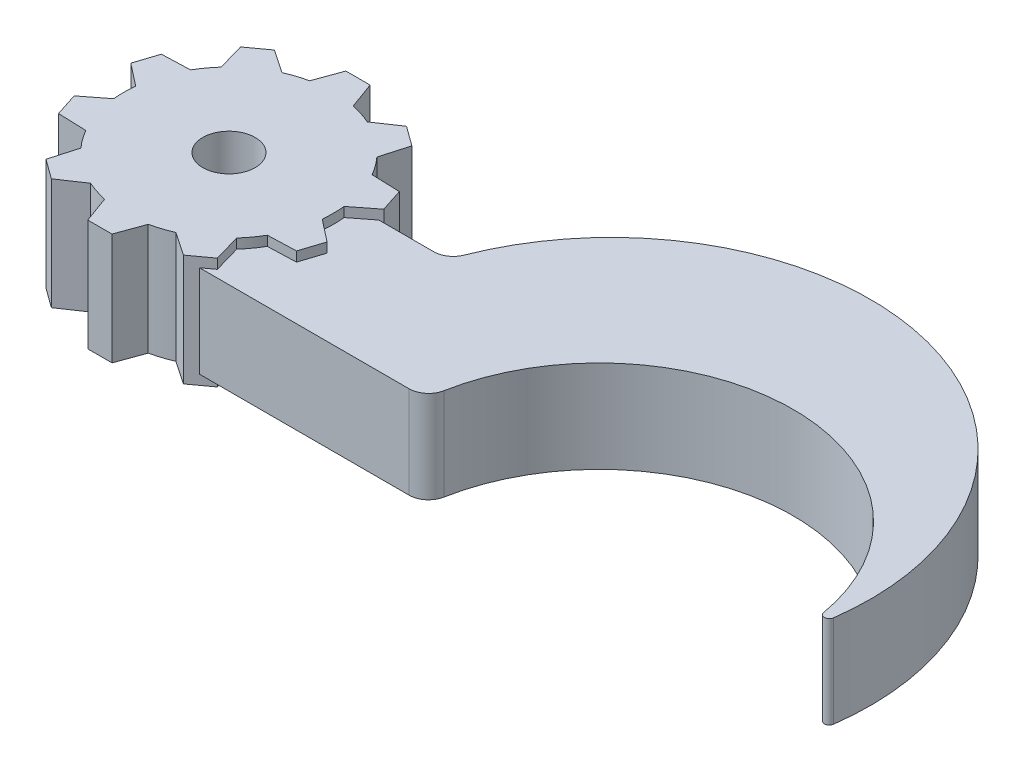
from build123d import *

# Parameters (mm, degrees)
SKETCH1_R           = 2.7
BOSS_EXTRUDE1_DEPTH = 11.5
BOSS_EXTRUDE3_START = 1
BOSS_EXTRUDE3_DEPTH = 9.5


with BuildPart() as part:
    # Sketch1 → Boss-Extrude1 (new body)
    with BuildSketch(Plane(origin=(0, 0, 0), x_dir=(1, 0, 0), z_dir=(0, 1, 0))):
        with BuildLine():
            Line((1.25, 13.3), (-1.25, 13.3))
            Line((-1.25, 13.3), (-2.24585645, 10.563906891))
            ThreePointArc((-2.24585645, 10.563906891), (-3.337383539, 10.271410376), (-4.392372642, 9.866461502))
            Line((-4.392372642, 9.866461502), (-6.806272613, 11.494657591))
            Line((-6.806272613, 11.494657591), (-8.828815098, 10.02519446))
            Line((-8.828815098, 10.02519446), (-8.026244712, 7.226298902))
            ThreePointArc((-8.026244712, 7.226298902), (-8.737383539, 6.348080725), (-9.352864677, 5.400363168))
            Line((-9.352864677, 5.400363168), (-12.262780424, 5.298746671))
            Line((-12.262780424, 5.298746671), (-13.03532291, 2.92110538))
            Line((-13.03532291, 2.92110538), (-10.740880296, 1.128490345))
            ThreePointArc((-10.740880296, 1.128490345), (-10.8, 0), (-10.740880296, -1.128490345))
            Line((-10.740880296, -1.128490345), (-13.03532291, -2.92110538))
            Line((-13.03532291, -2.92110538), (-12.262780424, -5.298746671))
            Line((-12.262780424, -5.298746671), (-9.352864677, -5.400363168))
            ThreePointArc((-9.352864677, -5.400363168), (-8.737383539, -6.348080725), (-8.026244712, -7.226298902))
            Line((-8.026244712, -7.226298902), (-8.828815098, -10.02519446))
            Line((-8.828815098, -10.02519446), (-6.806272613, -11.494657591))
            Line((-6.806272613, -11.494657591), (-4.392372642, -9.866461502))
            ThreePointArc((-4.392372642, -9.866461502), (-3.337383539, -10.271410376), (-2.24585645, -10.563906891))
            Line((-2.24585645, -10.563906891), (-1.25, -13.3))
            Line((-1.25, -13.3), (1.25, -13.3))
            Line((1.25, -13.3), (2.24585645, -10.563906891))
            ThreePointArc((2.24585645, -10.563906891), (3.337383539, -10.271410376), (4.392372642, -9.866461502))
            Line((4.392372642, -9.866461502), (6.806272613, -11.494657591))
            Line((6.806272613, -11.494657591), (8.828815098, -10.02519446))
            Line((8.828815098, -10.02519446), (8.026244712, -7.226298902))
            ThreePointArc((8.026244712, -7.226298902), (8.737383539, -6.348080725), (9.352864677, -5.400363168))
            Line((9.352864677, -5.400363168), (12.262780424, -5.298746671))
            Line((12.262780424, -5.298746671), (13.03532291, -2.92110538))
            Line((13.03532291, -2.92110538), (10.740880296, -1.128490345))
            ThreePointArc((10.740880296, -1.128490345), (10.8, 0), (10.740880296, 1.128490345))
            Line((10.740880296, 1.128490345), (13.03532291, 2.92110538))
            Line((13.03532291, 2.92110538), (12.262780424, 5.298746671))
            Line((12.262780424, 5.298746671), (9.352864677, 5.400363168))
            ThreePointArc((9.352864677, 5.400363168), (8.737383539, 6.348080725), (8.026244712, 7.226298902))
            Line((8.026244712, 7.226298902), (8.828815098, 10.02519446))
            Line((8.828815098, 10.02519446), (6.806272613, 11.494657591))
            Line((6.806272613, 11.494657591), (4.392372642, 9.866461502))
            ThreePointArc((4.392372642, 9.866461502), (3.337383539, 10.271410376), (2.24585645, 10.563906891))
            Line((2.24585645, 10.563906891), (1.25, 13.3))
        make_face()
        Circle(SKETCH1_R, mode=Mode.SUBTRACT)
    extrude(amount=BOSS_EXTRUDE1_DEPTH)

    # Sketch1_4 → Boss-Extrude3 (add)
    with BuildSketch(Plane(origin=(0, 0, 0), x_dir=(1, 0, 0), z_dir=(0, 1, 0)).offset(BOSS_EXTRUDE3_START)):
        with BuildLine():
            ThreePointArc((10.457055035, 2.7), (10.770443359, 0.798467184), (10.740880296, -1.128490345))
            Line((10.740880296, -1.128490345), (13.03532291, -2.92110538))
            Line((13.03532291, -2.92110538), (12.262780424, -5.298746671))
            Line((12.262780424, -5.298746671), (9.352864677, -5.400363168))
            ThreePointArc((9.352864677, -5.400363168), (8.737383539, -6.348080725), (8.026244712, -7.226298902))
            Line((8.026244712, -7.226298902), (8.828815098, -10.02519446))
            Line((8.828815098, -10.02519446), (7.762386761, -10.8))
            Line((7.762386761, -10.8), (29.369189077, -10.8))
            ThreePointArc((29.369189077, -10.8), (30.646867306, -10.338680715), (31.335127928, -9.167538342))
            ThreePointArc((31.335127928, -9.167538342), (51.109657071, 7.156746799), (70.69491969, -9.394137658))
            ThreePointArc((70.69491969, -9.394137658), (71.19716993, -9.807823175), (71.682924587, -9.374887357))
            ThreePointArc((71.682924587, -9.374887357), (51.897130707, 20.096844573), (20.274570163, 3.970025697))
            ThreePointArc((20.274570163, 3.970025697), (19.539499219, 3.047736612), (18.412545051, 2.7))
            Line((18.412545051, 2.7), (10.457055035, 2.7))
        make_face()
    extrude(amount=BOSS_EXTRUDE3_DEPTH)


solid = part.part
